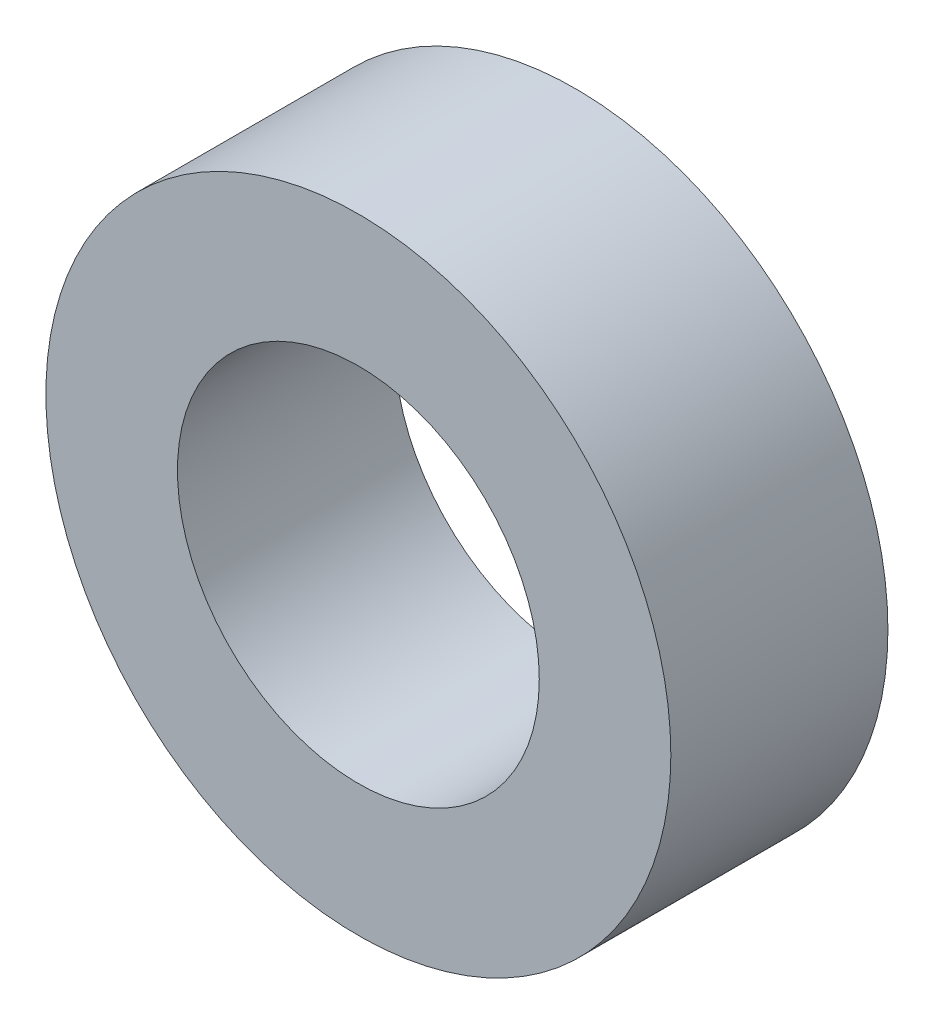
from build123d import *

# Parameters (mm, degrees)
SKETCH1_R           = 4.75
SKETCH1_R_2         = 2.75
BOSS_EXTRUDE1_DEPTH = 3.3


with BuildPart() as part:
    # Sketch1 → Boss-Extrude1 (new body)
    with BuildSketch(Plane.XY):
        Circle(SKETCH1_R)
        Circle(SKETCH1_R_2, mode=Mode.SUBTRACT)
    extrude(amount=BOSS_EXTRUDE1_DEPTH)


solid = part.part
